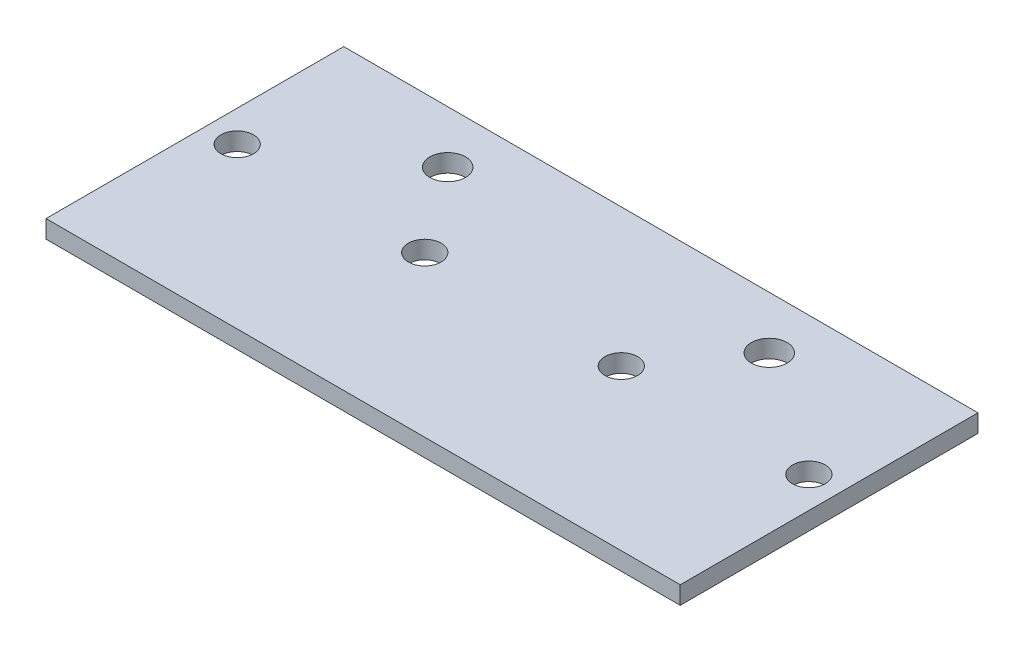
from build123d import *

# Parameters (mm, degrees)
SKETCH1_W           = 106.5
SKETCH1_H           = 50
BOSS_EXTRUDE1_DEPTH = 3
SKETCH2_R           = 2.75
SKETCH2_R_2         = 3
CUT_EXTRUDE1_DEPTH  = 4


with BuildPart() as part:
    # Sketch1 → Boss-Extrude1 (new body)
    with BuildSketch(Plane(origin=(0, 0, 0), x_dir=(1, 0, 0), z_dir=(0, 1, 0))):
        Rectangle(SKETCH1_W, SKETCH1_H)
    extrude(amount=BOSS_EXTRUDE1_DEPTH)

    # Sketch2 → Cut-Extrude1 (cut, through all)
    with BuildSketch(Plane(origin=(0, 3, 0), x_dir=(1, 0, 0), z_dir=(0, 1, 0))):
        with Locations((48, 1.85)):
            Circle(SKETCH2_R)
        with Locations((16.5, 1.85)):
            Circle(SKETCH2_R)
        with Locations((-16.5, 1.85)):
            Circle(SKETCH2_R)
        with Locations((-48, 1.85)):
            Circle(SKETCH2_R)
        with Locations((27, 16.2)):
            Circle(SKETCH2_R_2)
        with Locations((-27, 16.2)):
            Circle(SKETCH2_R_2)
    extrude(amount=-CUT_EXTRUDE1_DEPTH, mode=Mode.SUBTRACT)


solid = part.part
